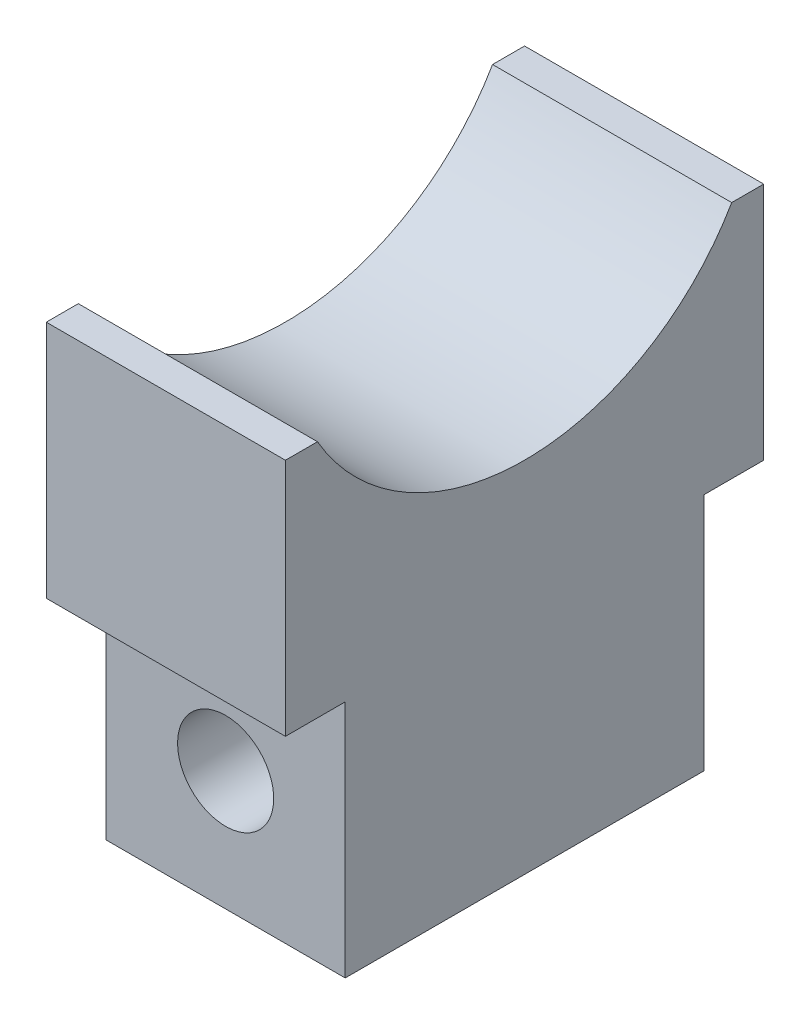
from build123d import *

# Parameters (mm, degrees)
SKETCH1_W               = 12.7
SKETCH1_H               = 25.4
BOSS_EXTRUDE1_DEPTH     = 25.4
SKETCH2_OUTSIDE_W       = 35.02
SKETCH2_OUTSIDE_H       = 35.02
CUT_EXTRUDE1_DEPTH      = 13.7
F_1_4_20_TAPPED_HOLE2_D = 5.1054


with BuildPart() as part:
    # Sketch1 → Boss-Extrude1 (new body)
    with BuildSketch(Plane.XY):
        Rectangle(SKETCH1_W, SKETCH1_H)
    extrude(amount=BOSS_EXTRUDE1_DEPTH)

    # Sketch2 outside → Cut-Extrude1 (cut, through all)
    with BuildSketch(Plane.ZY.offset(6.35)):
        with Locations((12.7, 0)):
            Rectangle(SKETCH2_OUTSIDE_W, SKETCH2_OUTSIDE_H)
        with BuildLine():
            Line((23.698522628, 12.7), (25.4, 12.7))
            Line((25.4, 12.7), (25.4, 0))
            Line((25.4, 0), (22.225, 0))
            Line((22.225, 0), (22.225, -12.7))
            Line((22.225, -12.7), (3.175, -12.7))
            Line((3.175, -12.7), (3.175, 0))
            Line((3.175, 0), (0, 0))
            Line((0, 0), (0, 12.7))
            Line((0, 12.7), (1.701477372, 12.7))
            ThreePointArc((1.701477372, 12.7), (12.7, 6.35), (23.698522628, 12.7))
        make_face(mode=Mode.SUBTRACT)
    extrude(amount=-CUT_EXTRUDE1_DEPTH, mode=Mode.SUBTRACT)

    # 1/4-20 Tapped Hole2 (through all)
    with Locations(Plane(origin=(0, -6.35, 3.175), x_dir=(0, -1, 0), z_dir=(0, 0, -1))):
        with Locations((0, 0)):
            Hole(F_1_4_20_TAPPED_HOLE2_D / 2)


solid = part.part
